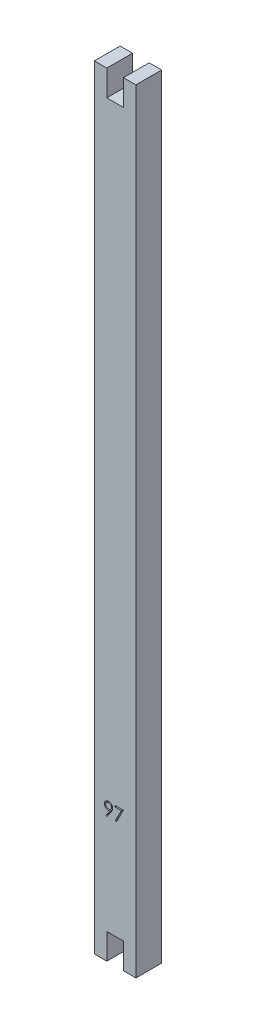
from build123d import *

# Parameters (mm, degrees)
BOSS_EXTRUDE1_DEPTH = 6.2
CUT_EXTRUDE1_DEPTH  = 1


with BuildPart() as part:
    # Sketch2 → Boss-Extrude1 (new body)
    with BuildSketch(Plane.XY):
        Polygon((0, 0), (0, 186.19), (3, 186.19), (3, 179.99), (7, 179.99), (7, 186.19), (10, 186.19), (10, 0), (7, 0), (7, 6.2), (3, 6.2), (3, 0), align=None)
    extrude(amount=BOSS_EXTRUDE1_DEPTH)

    # Sketch3 → Cut-Extrude1 (cut)
    with BuildSketch(Plane.XY.offset(6.2)):
        with BuildLine():
            Line((3.072648213, 30.209362795), (2.844953902, 30.367731185))
            Line((2.844953902, 30.367731185), (3.72774637, 31.658210953))
            add(Edge.make_bspline(
                [(3.72774637, 31.658210953), (3.671421203, 31.651322959), (3.560513808, 31.637760117), (3.448810866, 31.635268509), (3.393837115, 31.634042283)],
                knots=[0, 0, 0, 0, 0.000170115, 0.000334967, 0.000334967, 0.000334967, 0.000334967], degree=3))
            add(Edge.make_bspline(
                [(3.393837115, 31.634042283), (3.360506829, 31.634895973), (3.295082392, 31.636571694), (3.198896536, 31.649853906), (3.106471777, 31.670310093), (3.018053147, 31.700834321), (2.933308311, 31.73876941), (2.852422271, 31.78581113), (2.775503913, 31.841152552), (2.703379334, 31.904501051), (2.637782256, 31.974058999), (2.579341122, 32.04767876), (2.530771667, 32.126215534), (2.49042505, 32.208067233), (2.45982671, 32.294410316), (2.437544979, 32.384262271), (2.423826844, 32.478252832), (2.422194807, 32.542229201), (2.421366162, 32.574712355)],
                knots=[0, 0, 0, 0, 9.9954e-05, 0.000196201, 0.000290782, 0.000383503, 0.000476303, 0.000568919, 0.000663705, 0.000760153, 0.000856434, 0.000950205, 0.001041624, 0.001132931, 0.001223461, 0.001315861, 0.001410305, 0.001507717, 0.001507717, 0.001507717, 0.001507717], degree=3))
            add(Edge.make_bspline(
                [(2.421366162, 32.574712355), (2.422939542, 32.619133918), (2.426027768, 32.706324436), (2.450882137, 32.833717927), (2.491758302, 32.954174291), (2.548752615, 33.067376824), (2.620539113, 33.171697109), (2.706816191, 33.265684919), (2.807059073, 33.348003465), (2.91898419, 33.418764307), (3.03995443, 33.475673911), (3.166653856, 33.517619562), (3.298111665, 33.542292712), (3.387163766, 33.5455456), (3.431998173, 33.547183308)],
                knots=[0, 0, 0, 0, 0.000133185, 0.000261414, 0.000387724, 0.00051373, 0.000640399, 0.00076644, 0.000895188, 0.001028407, 0.001162697, 0.001295241, 0.001427846, 0.0015623, 0.0015623, 0.0015623, 0.0015623], degree=3))
            add(Edge.make_bspline(
                [(3.431998173, 33.547183308), (3.475984097, 33.545523089), (3.562896136, 33.542242652), (3.690702591, 33.518217909), (3.813113371, 33.47772607), (3.929449895, 33.421769358), (4.037163504, 33.351628249), (4.134024419, 33.268049074), (4.217822229, 33.170979774), (4.288419607, 33.062768073), (4.345088858, 32.946502311), (4.385975857, 32.825141182), (4.411145116, 32.699557484), (4.414316784, 32.614472497), (4.415917444, 32.571532267)],
                knots=[0, 0, 0, 0, 0.000131915, 0.000260652, 0.000388569, 0.000517718, 0.000646848, 0.000773094, 0.000900237, 0.001030248, 0.001159674, 0.001287189, 0.001413545, 0.001542287, 0.001542287, 0.001542287, 0.001542287], degree=3))
            add(Edge.make_bspline(
                [(4.415917444, 32.571532267), (4.414848459, 32.538200421), (4.41268029, 32.470595109), (4.397498068, 32.367879012), (4.3717169, 32.263148254), (4.342460002, 32.174500806), (4.314218678, 32.101286713), (4.287638366, 32.043454922), (4.258145198, 31.982584491), (4.223747461, 31.919313691), (4.186770235, 31.852835963), (4.144987891, 31.783818071), (4.099353551, 31.712167398), (4.066850877, 31.663864683), (4.050207308, 31.639130424)],
                knots=[0, 0, 0, 0, 9.9984e-05, 0.000202793, 0.000310776, 0.000423207, 0.000482616, 0.000546097, 0.000614079, 0.0006855, 0.000762103, 0.000842274, 0.000927493, 0.001016928, 0.001016928, 0.001016928, 0.001016928], degree=3))
            Line((4.050207308, 31.639130424), (3.072648213, 30.209362795))
        make_face()
        with BuildLine():
            add(Edge.make_bspline(
                [(3.446626579, 31.959683308), (3.471876006, 31.960373085), (3.521028056, 31.961715846), (3.593034606, 31.969888515), (3.661001562, 31.984379203), (3.725110481, 32.005170656), (3.786004171, 32.030259205), (3.842715411, 32.062201507), (3.895291665, 32.100316597), (3.944084999, 32.143142826), (3.98741377, 32.190722998), (4.026006377, 32.240522516), (4.058809177, 32.292759984), (4.08472015, 32.348089586), (4.106024015, 32.405164482), (4.120736069, 32.46490379), (4.128886142, 32.526996268), (4.1302755, 32.569177193), (4.130981547, 32.590612795)],
                knots=[0, 0, 0, 0, 7.5753e-05, 0.000147465, 0.000217073, 0.000283852, 0.000349411, 0.000414338, 0.000478589, 0.000543925, 0.000608743, 0.000671332, 0.000732749, 0.000793345, 0.000854313, 0.000915245, 0.00097749, 0.001041807, 0.001041807, 0.001041807, 0.001041807], degree=3))
            add(Edge.make_bspline(
                [(4.130981547, 32.590612795), (4.130374061, 32.612057349), (4.129176936, 32.654316472), (4.119572743, 32.716500879), (4.102677005, 32.776094051), (4.080007065, 32.833422241), (4.050143706, 32.888014436), (4.014308401, 32.940556034), (3.971733965, 32.990713892), (3.922745923, 33.037308363), (3.869918864, 33.080259672), (3.813621124, 33.118165612), (3.754316736, 33.14993484), (3.692367506, 33.176150334), (3.627644361, 33.196608017), (3.5601856, 33.211319483), (3.48965034, 33.219458146), (3.441770173, 33.220838722), (3.417369768, 33.221542283)],
                knots=[0, 0, 0, 0, 6.4316e-05, 0.000126743, 0.000188161, 0.000249812, 0.000311283, 0.000374438, 0.00044032, 0.000508243, 0.00057698, 0.000644365, 0.000711521, 0.0007785, 0.000845884, 0.000914871, 0.00098532, 0.001058531, 0.001058531, 0.001058531, 0.001058531], degree=3))
            add(Edge.make_bspline(
                [(3.417369768, 33.221542283), (3.393181571, 33.220837585), (3.34572453, 33.219454975), (3.275816328, 33.211334953), (3.208813697, 33.196509078), (3.144278084, 33.17615981), (3.082330695, 33.149932885), (3.023029104, 33.118163947), (2.966718196, 33.080268397), (2.913941785, 33.037274568), (2.864867241, 32.990930775), (2.823024797, 32.940336307), (2.787107481, 32.888041767), (2.757285157, 32.833414977), (2.734604302, 32.77609599), (2.717711486, 32.716500354), (2.708106508, 32.654316609), (2.70690949, 32.612057395), (2.706302059, 32.590612795)],
                knots=[0, 0, 0, 0, 7.2576e-05, 0.000142393, 0.000210758, 0.000278143, 0.000345121, 0.000412278, 0.000479663, 0.0005484, 0.000616323, 0.000681795, 0.00074495, 0.000806421, 0.000868072, 0.00092949, 0.000991917, 0.001056233, 0.001056233, 0.001056233, 0.001056233], degree=3))
            add(Edge.make_bspline(
                [(2.706302059, 32.590612795), (2.706851721, 32.569160501), (2.707935754, 32.52685265), (2.718393106, 32.464689422), (2.73588126, 32.405100846), (2.759303136, 32.347507519), (2.790147435, 32.292469476), (2.827996926, 32.240247655), (2.872361243, 32.190250068), (2.922647335, 32.143253526), (2.977682024, 32.100116909), (3.036461929, 32.06244292), (3.097975139, 32.030627203), (3.162438189, 32.005098947), (3.229373358, 31.984586938), (3.299382227, 31.969915222), (3.372233271, 31.961794237), (3.421590897, 31.960393702), (3.446626579, 31.959683308)],
                knots=[0, 0, 0, 0, 6.4316e-05, 0.000126844, 0.000188436, 0.000250326, 0.000312966, 0.000377217, 0.000443451, 0.000513196, 0.000583426, 0.000652939, 0.000722346, 0.000790847, 0.000860662, 0.000932137, 0.001005113, 0.00108023, 0.00108023, 0.00108023, 0.00108023], degree=3))
        make_face(mode=Mode.SUBTRACT)
        Polygon((5.026494367, 33.465773052), (6.980340521, 33.465773052), (5.311430264, 30.209362795), (5.065291442, 30.34483455), (6.498239159, 33.140132026), (5.026494367, 33.140132026), align=None)
    extrude(amount=-CUT_EXTRUDE1_DEPTH, mode=Mode.SUBTRACT)


solid = part.part
